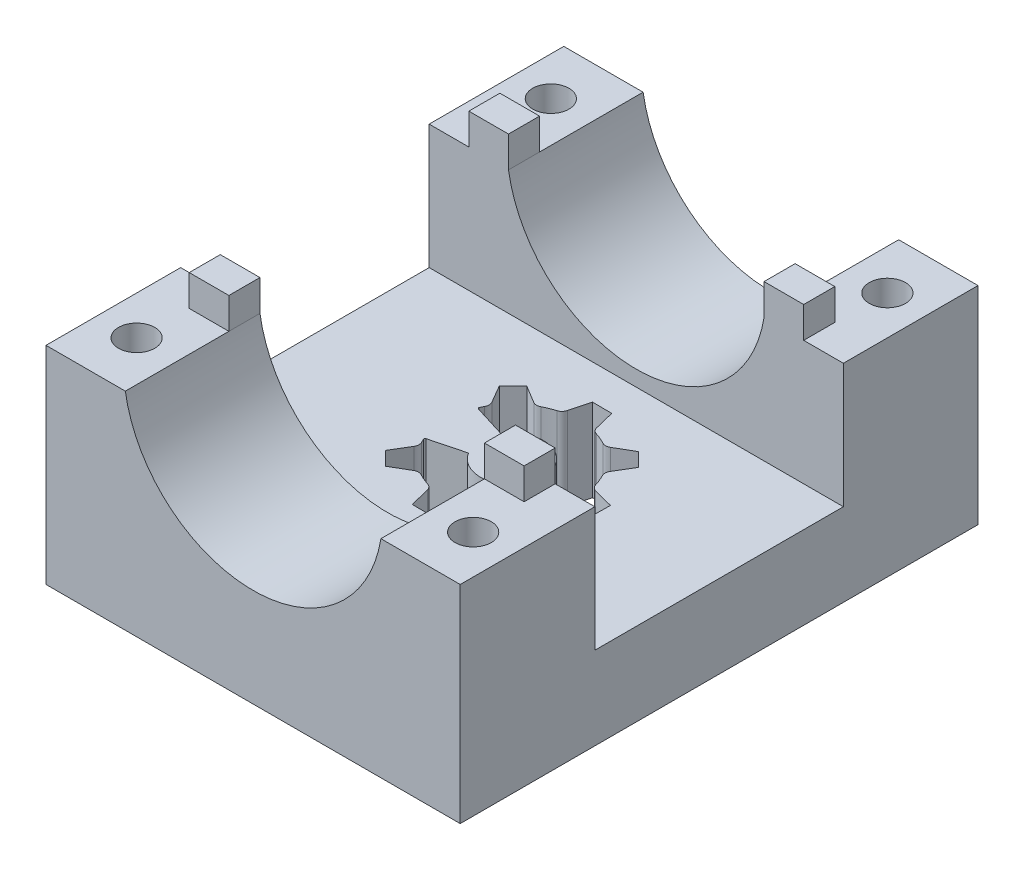
from build123d import *

# Parameters (mm, degrees)
CROQUIS1_W              = 40
CROQUIS1_H              = 50
SALIENTE_EXTRUIR1_DEPTH = 20
CROQUIS2_R              = 12.5
CORTAR_EXTRUIR1_DEPTH   = 51
CROQUIS3_R              = 1.75
CORTAR_EXTRUIR2_DEPTH   = 21
CORTAR_EXTRUIR3_DEPTH   = 41
CROQUIS5_W              = 3.830518661
CROQUIS5_H              = 3
SALIENTE_EXTRUIR3_DEPTH = 3
CORTAR_EXTRUIR5_DEPTH   = 24


with BuildPart() as part:
    # Croquis1 → Saliente-Extruir1 (new body)
    with BuildSketch(Plane(origin=(0, 0, 0), x_dir=(1, 0, 0), z_dir=(0, 1, 0))):
        with Locations((20, 25)):
            Rectangle(CROQUIS1_W, CROQUIS1_H)
    extrude(amount=SALIENTE_EXTRUIR1_DEPTH)

    # Croquis2 → Cortar-Extruir1 (cut, through all)
    with BuildSketch(Plane.XY):
        with Locations((20, 22)):
            Circle(CROQUIS2_R)
    extrude(amount=-CORTAR_EXTRUIR1_DEPTH, mode=Mode.SUBTRACT)

    # Croquis3 → Cortar-Extruir2 (cut, through all)
    with BuildSketch(Plane(origin=(0, 20, 0), x_dir=(1, 0, 0), z_dir=(0, 1, 0))):
        with Locations((3.75, 45)):
            Circle(CROQUIS3_R)
        with Locations((36.25, 45)):
            Circle(CROQUIS3_R)
        with Locations((36.25, 5)):
            Circle(CROQUIS3_R)
        with Locations((3.75, 5)):
            Circle(CROQUIS3_R)
    extrude(amount=-CORTAR_EXTRUIR2_DEPTH, mode=Mode.SUBTRACT)

    # Croquis4 → Cortar-Extruir3 (cut, through all)
    with BuildSketch(Plane(origin=(40, 0, 0), x_dir=(0, 0, -1), z_dir=(1, 0, 0))):
        Polygon((25, 20), (37, 20), (37, 8), (13, 8), (13, 20), align=None)
    extrude(amount=-CORTAR_EXTRUIR3_DEPTH, mode=Mode.SUBTRACT)

    # Croquis5 → Saliente-Extruir3 (add)
    with BuildSketch(Plane(origin=(0, 20, 0), x_dir=(1, 0, 0), z_dir=(0, 1, 0))):
        with Locations((5.745777991, 38.5)):
            Rectangle(CROQUIS5_W, CROQUIS5_H)
        with Locations((34.25422201, 38.5)):
            Rectangle(CROQUIS5_W, CROQUIS5_H)
        with Locations((34.25422201, 11.5)):
            Rectangle(CROQUIS5_W, CROQUIS5_H)
        with Locations((5.745777991, 11.5)):
            Rectangle(CROQUIS5_W, CROQUIS5_H)
    extrude(amount=SALIENTE_EXTRUIR3_DEPTH)

    # Croquis6 → Cortar-Extruir5 (cut, through all)
    with BuildSketch(Plane.XZ):
        with BuildLine():
            Line((13.188139939, -19.615331161), (14.501537669, -18.279657152))
            Line((14.501537669, -18.279657152), (16.224863288, -19.28260268))
            ThreePointArc((16.224863288, -19.28260268), (16.575067996, -19.380217097), (16.928320792, -19.294284721))
            ThreePointArc((16.928320792, -19.294284721), (17.469957789, -19.034324312), (18.033343063, -18.825644933))
            ThreePointArc((18.033343063, -18.825644933), (18.340671144, -18.631425053), (18.513928995, -18.31181024))
            Line((18.513928995, -18.31181024), (18.990823409, -16.375751708))
            Line((18.990823409, -16.375751708), (20.864, -16.36))
            Line((20.864, -16.36), (21.373385647, -18.287764816))
            ThreePointArc((21.373385647, -18.287764816), (21.551993955, -18.604420755), (21.862544768, -18.793444837))
            ThreePointArc((21.862544768, -18.793444837), (22.429359729, -18.992620263), (22.975291881, -19.243435206))
            ThreePointArc((22.975291881, -19.243435206), (23.329939845, -19.323414782), (23.678453448, -19.219924782))
            Line((23.678453448, -19.219924782), (25.384668839, -18.188139939))
            Line((25.384668839, -18.188139939), (26.720342848, -19.501537669))
            Line((26.720342848, -19.501537669), (25.71739732, -21.224863288))
            ThreePointArc((25.71739732, -21.224863288), (25.619782903, -21.575067996), (25.705715279, -21.928320792))
            ThreePointArc((25.705715279, -21.928320792), (25.965675688, -22.469957789), (26.174355067, -23.033343063))
            ThreePointArc((26.174355067, -23.033343063), (26.368574947, -23.340671144), (26.68818976, -23.513928995))
            Line((26.68818976, -23.513928995), (28.624248292, -23.990823409))
            Line((28.624248292, -23.990823409), (28.64, -25.864))
            Line((28.64, -25.864), (26.712235184, -26.373385647))
            ThreePointArc((26.712235184, -26.373385647), (26.395579245, -26.551993955), (26.206555163, -26.862544768))
            ThreePointArc((26.206555163, -26.862544768), (26.007379737, -27.429359729), (25.756564794, -27.975291881))
            ThreePointArc((25.756564794, -27.975291881), (25.676585218, -28.329939845), (25.780075218, -28.678453448))
            Line((25.780075218, -28.678453448), (26.811860061, -30.384668839))
            Line((26.811860061, -30.384668839), (25.498462331, -31.720342848))
            Line((25.498462331, -31.720342848), (23.775136712, -30.71739732))
            ThreePointArc((23.775136712, -30.71739732), (23.424932004, -30.619782903), (23.071679208, -30.705715279))
            ThreePointArc((23.071679208, -30.705715279), (22.530042211, -30.965675688), (21.966656937, -31.174355067))
            ThreePointArc((21.966656937, -31.174355067), (21.659328856, -31.368574947), (21.486071005, -31.68818976))
            Line((21.486071005, -31.68818976), (21.009176591, -33.624248292))
            Line((21.009176591, -33.624248292), (19.136, -33.64))
            Line((19.136, -33.64), (18.626614353, -31.712235184))
            ThreePointArc((18.626614353, -31.712235184), (18.448006045, -31.395579245), (18.137455232, -31.206555163))
            ThreePointArc((18.137455232, -31.206555163), (17.570640271, -31.007379737), (17.024708119, -30.756564794))
            ThreePointArc((17.024708119, -30.756564794), (16.670060155, -30.676585218), (16.321546552, -30.780075218))
            Line((16.321546552, -30.780075218), (14.615331161, -31.811860061))
            Line((14.615331161, -31.811860061), (13.279657152, -30.498462331))
            Line((13.279657152, -30.498462331), (14.28260268, -28.775136712))
            ThreePointArc((14.28260268, -28.775136712), (14.380217097, -28.424932004), (14.294284721, -28.071679208))
            ThreePointArc((14.294284721, -28.071679208), (14.208247472, -27.906200724), (14.127008205, -27.738314697))
            ThreePointArc((14.127008205, -27.738314697), (14.125953752, -27.626452127), (14.209575503, -27.552143653))
            Line((14.209575503, -27.552143653), (17.384042323, -26.571445385))
            ThreePointArc((17.384042323, -26.571445385), (23.05159058, -25.021681648), (17.406635637, -23.391542216))
            Line((17.406635637, -23.391542216), (14.170602247, -22.54767412))
            ThreePointArc((14.170602247, -22.54767412), (14.082937198, -22.475491969), (14.08129489, -22.361945826))
            ThreePointArc((14.08129489, -22.361945826), (14.159930296, -22.19215637), (14.243435206, -22.024708119))
            ThreePointArc((14.243435206, -22.024708119), (14.323414782, -21.670060155), (14.219924782, -21.321546552))
            Line((14.219924782, -21.321546552), (13.188139939, -19.615331161))
        make_face()
    extrude(amount=-CORTAR_EXTRUIR5_DEPTH, mode=Mode.SUBTRACT)


solid = part.part
